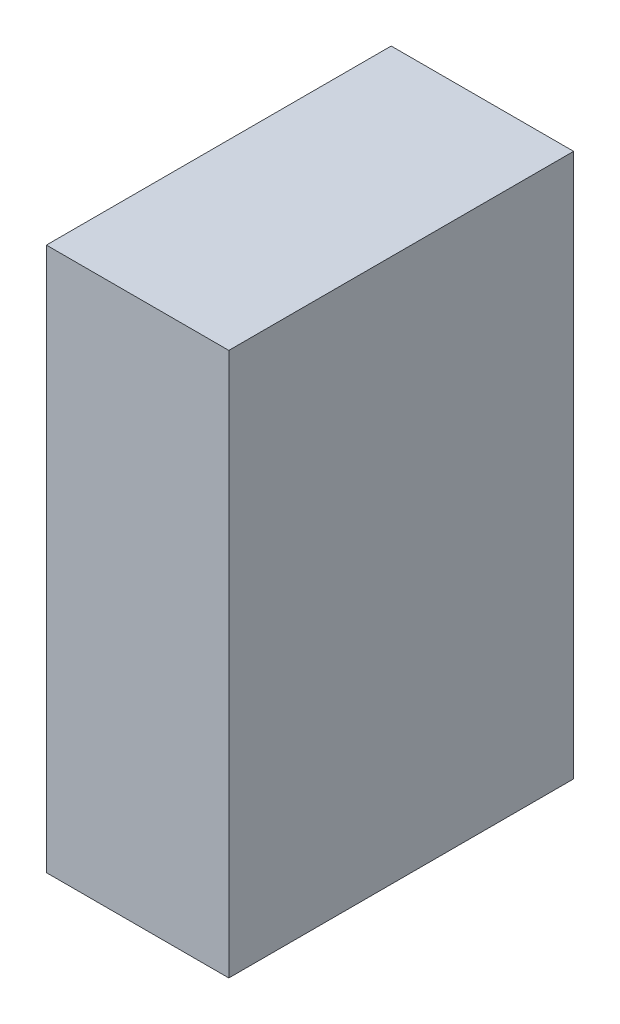
from build123d import *

# Parameters (mm, degrees)
SKETCH2_W           = 29.1
SKETCH2_H           = 55
BOSS_EXTRUDE1_DEPTH = 86.7


with BuildPart() as part:
    # Sketch2 → Boss-Extrude1 (new body)
    with BuildSketch(Plane(origin=(0, 0, 0), x_dir=(1, 0, 0), z_dir=(0, 1, 0))):
        with Locations((14.55, 27.5)):
            Rectangle(SKETCH2_W, SKETCH2_H)
    extrude(amount=BOSS_EXTRUDE1_DEPTH)


solid = part.part
